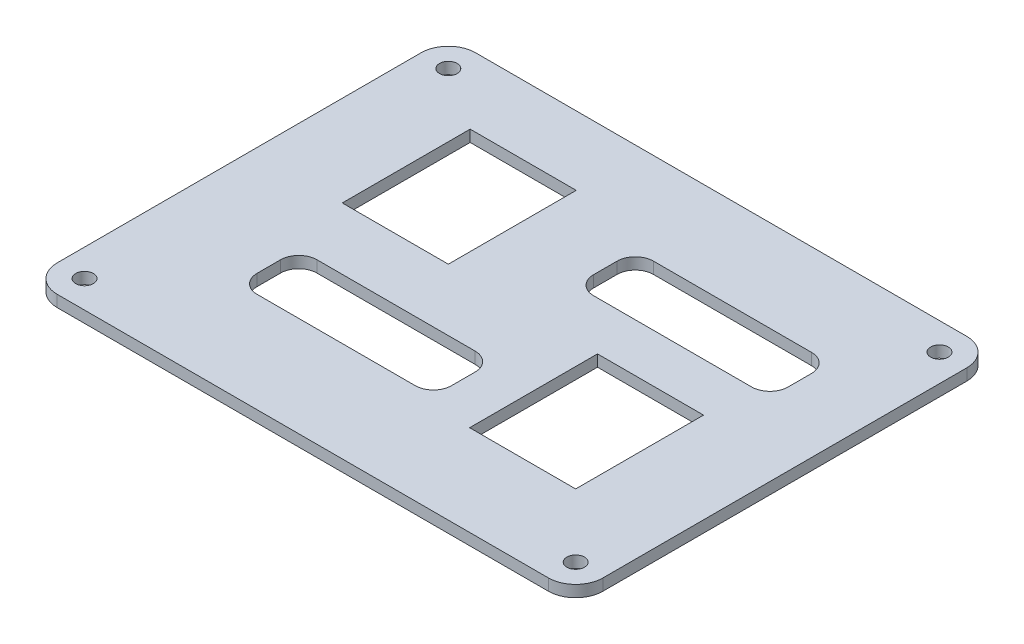
from build123d import *

# Parameters (mm, degrees)
SKETCH1_R           = 4.85
BOSS_EXTRUDE1_DEPTH = 6.35
SKETCH2_W           = 58.3
SKETCH2_H           = 70.3
CUT_EXTRUDE1_DEPTH  = 6.35
CUT_EXTRUDE2_DEPTH  = 6.35


with BuildPart() as part:
    # Sketch1 → Boss-Extrude1 (new body)
    with BuildSketch(Plane(origin=(0, 0, 0), x_dir=(1, 0, 0), z_dir=(0, 1, 0))):
        with BuildLine():
            Line((-37.814650179, 171.04710305), (232.185349821, 171.04710305))
            ThreePointArc((232.185349821, 171.04710305), (242.791951539, 166.653704768), (247.185349821, 156.04710305))
            Line((247.185349821, 156.04710305), (247.185349821, -43.95289695))
            ThreePointArc((247.185349821, -43.95289695), (242.791951539, -54.559498668), (232.185349821, -58.95289695))
            Line((232.185349821, -58.95289695), (-37.814650179, -58.95289695))
            ThreePointArc((-37.814650179, -58.95289695), (-48.421251896, -54.559498668), (-52.814650179, -43.95289695))
            Line((-52.814650179, -43.95289695), (-52.814650179, 156.04710305))
            ThreePointArc((-52.814650179, 156.04710305), (-48.421251896, 166.653704768), (-37.814650179, 171.04710305))
        make_face()
        with Locations((-37.814650179, 156.04710305)):
            Circle(SKETCH1_R, mode=Mode.SUBTRACT)
        with Locations((232.185349821, 156.04710305)):
            Circle(SKETCH1_R, mode=Mode.SUBTRACT)
        with Locations((232.185349821, -43.95289695)):
            Circle(SKETCH1_R, mode=Mode.SUBTRACT)
        with Locations((-37.814650179, -43.95289695)):
            Circle(SKETCH1_R, mode=Mode.SUBTRACT)
    extrude(amount=BOSS_EXTRUDE1_DEPTH)

    # Sketch2 → Cut-Extrude1 (cut)
    with BuildSketch(Plane.XZ):
        with Locations((168.185349821, -26.04710305)):
            Rectangle(SKETCH2_W, SKETCH2_H)
        with Locations((26.185349821, -98.04710305)):
            Rectangle(SKETCH2_W, SKETCH2_H)
    extrude(amount=-CUT_EXTRUDE1_DEPTH, mode=Mode.SUBTRACT)

    # Sketch3 → Cut-Extrude2 (cut)
    with BuildSketch(Plane.XZ):
        with BuildLine():
            Line((17.107545151, -28.900683481), (104.041408607, -28.900683481))
            ThreePointArc((104.041408607, -28.900683481), (111.112476419, -25.971751293), (114.041408607, -18.900683481))
            Line((114.041408607, -18.900683481), (114.041408607, -5.971842988))
            ThreePointArc((114.041408607, -5.971842988), (111.112476419, 1.099224823), (104.041408607, 4.028157012))
            Line((104.041408607, 4.028157012), (17.107545151, 4.028157012))
            ThreePointArc((17.107545151, 4.028157012), (10.03647734, 1.099224823), (7.107545151, -5.971842988))
            Line((7.107545151, -5.971842988), (7.107545151, -18.900683481))
            ThreePointArc((7.107545151, -18.900683481), (10.03647734, -25.971751293), (17.107545151, -28.900683481))
        make_face()
        with BuildLine():
            Line((110.251233871, -120.745362711), (197.185097326, -120.745362711))
            ThreePointArc((197.185097326, -120.745362711), (204.256165138, -117.816430523), (207.185097326, -110.745362711))
            Line((207.185097326, -110.745362711), (207.185097326, -97.816522218))
            ThreePointArc((207.185097326, -97.816522218), (204.256165138, -90.745454407), (197.185097326, -87.816522218))
            Line((197.185097326, -87.816522218), (110.251233871, -87.816522218))
            ThreePointArc((110.251233871, -87.816522218), (103.180166059, -90.745454407), (100.251233871, -97.816522218))
            Line((100.251233871, -97.816522218), (100.251233871, -110.745362711))
            ThreePointArc((100.251233871, -110.745362711), (103.180166059, -117.816430523), (110.251233871, -120.745362711))
        make_face()
    extrude(amount=-CUT_EXTRUDE2_DEPTH, mode=Mode.SUBTRACT)


solid = part.part
